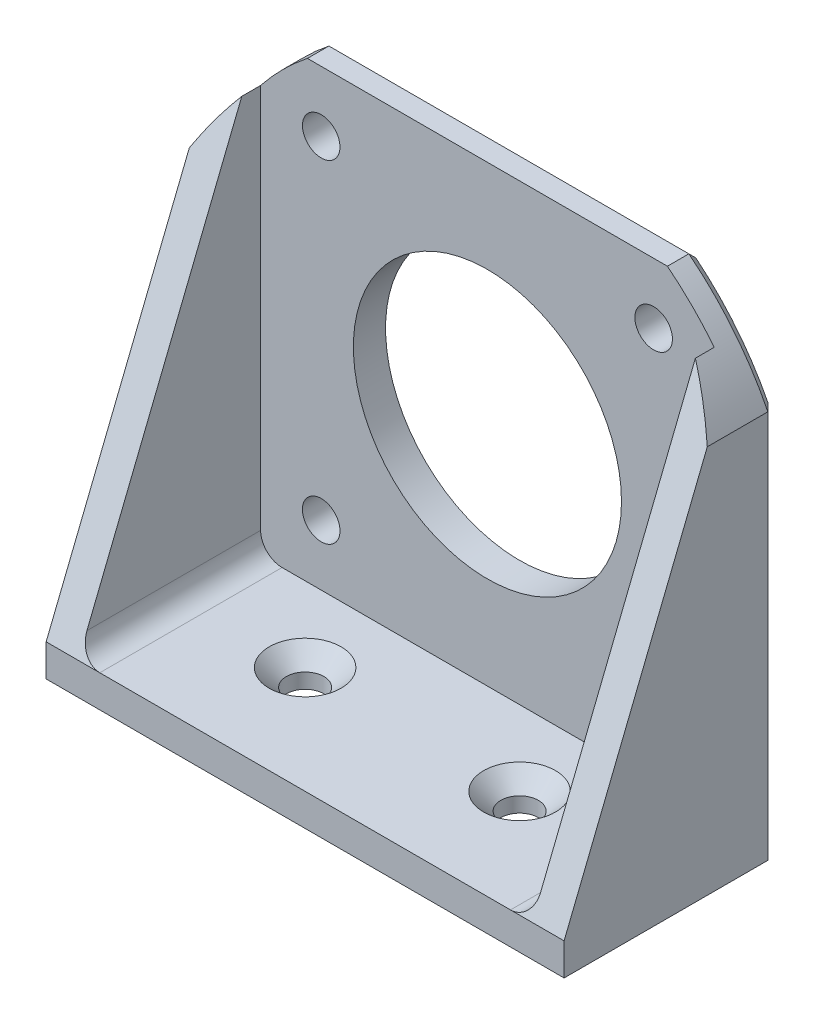
from build123d import *

# Parameters (mm, degrees)
SKETCH1_W           = 48.3
SKETCH1_H           = 20
BOSS_EXTRUDE1_DEPTH = 3
SKETCH2_W           = 48.3
SKETCH2_H           = 3
BOSS_EXTRUDE2_DEPTH = 42.3
SKETCH3_R           = 12.5
SKETCH3_R_2         = 1.75
CUT_EXTRUDE1_DEPTH  = 55.076912819
RIB1_REACH          = 68.97
SKETCH4_WALL_W      = 181.528252596
SKETCH4_WALL_H      = 3
CUT_EXTRUDE2_DEPTH  = 56.093670235
SKETCH6_R           = 1.75
CUT_EXTRUDE3_DEPTH  = 50.724365255
FILLET1_R           = 2
CHAMFER2_SIZE       = 1
CHAMFER3_SIZE       = 1.6


with BuildPart() as part:
    # Sketch1 → Boss-Extrude1 (new body)
    with BuildSketch(Plane(origin=(0, 0, 0), x_dir=(1, 0, 0), z_dir=(0, 1, 0))):
        Rectangle(SKETCH1_W, SKETCH1_H)
    extrude(amount=BOSS_EXTRUDE1_DEPTH)

    # Sketch2 → Boss-Extrude2 (add)
    with BuildSketch(Plane(origin=(0, 3, 0), x_dir=(1, 0, 0), z_dir=(0, 1, 0))):
        with Locations((0, 8.5)):
            Rectangle(SKETCH2_W, SKETCH2_H)
    extrude(amount=BOSS_EXTRUDE2_DEPTH)

    # Sketch3 → Cut-Extrude1 (cut, through all)
    with BuildSketch(Plane.XY.offset(-7)):
        with Locations((0, 24.15)):
            Circle(SKETCH3_R)
        with Locations((-15.5, 39.65)):
            Circle(SKETCH3_R_2)
        with Locations((15.5, 39.65)):
            Circle(SKETCH3_R_2)
        with Locations((15.5, 8.65)):
            Circle(SKETCH3_R_2)
        with Locations((-15.5, 8.65)):
            Circle(SKETCH3_R_2)
    extrude(amount=-CUT_EXTRUDE1_DEPTH, mode=Mode.SUBTRACT)

    # Sketch4 wall → Rib1 (add, up to next)
    with BuildSketch(Plane(origin=(-24.15, 24.15, 1.5), x_dir=(0, -0.927870342081, 0.372902974359), z_dir=(0, 0.372902974359, 0.927870342081)), mode=Mode.PRIVATE) as rib1_sk1:
        with Locations((0, 1.5)):
            Rectangle(SKETCH4_WALL_W, SKETCH4_WALL_H)
    rib1_tool1 = extrude(rib1_sk1.sketch, amount=-RIB1_REACH, mode=Mode.PRIVATE) - part.part
    rib1 = rib1_tool1.solids().sort_by_distance((-24.15, 24.15, 1.5))[0]
    add(rib1)

    # Mirror1: Rib1 across plane
    add(rib1.mirror(Plane(origin=(0, 0, 0), x_dir=(0, 0, 1), z_dir=(1, 0, 0))))

    # Sketch5 → Cut-Extrude2 (cut, through all)
    with BuildSketch(Plane(origin=(0, 0, -10), x_dir=(-1, 0, 0), z_dir=(0, 0, -1))):
        with BuildLine():
            Line((-27, 24.15), (-32.102102735, 24.15))
            ThreePointArc((-32.102102735, 24.15), (0, 56.252102735), (32.102102735, 24.15))
            Line((32.102102735, 24.15), (27, 24.15))
            ThreePointArc((27, 24.15), (0, 51.15), (-27, 24.15))
        make_face()
    extrude(amount=-CUT_EXTRUDE2_DEPTH, mode=Mode.SUBTRACT)

    # Sketch6 → Cut-Extrude3 (cut, through all)
    with BuildSketch(Plane(origin=(0, 3, 0), x_dir=(1, 0, 0), z_dir=(0, 1, 0))):
        with Locations(Location((-10, 0, 0), (0, 0, 270))):
            Circle(SKETCH6_R)
        with Locations(Location((10, 0, 0), (0, 0, 270))):
            Circle(SKETCH6_R)
    extrude(amount=-CUT_EXTRUDE3_DEPTH, mode=Mode.SUBTRACT)

    # Fillet1
    fillet1_edges = [part.edges().sort_by_distance(p)[0] for p in [
        (-21.15, 3, 1.5),
        (21.15, 3, 1.5),
    ]]
    fillet(fillet1_edges, radius=FILLET1_R)

    # Chamfer2
    chamfer2_edges = [part.edges().sort_by_distance(p)[0] for p in [
        (0, 0, -10),
        (0, 45.3, -10),
        (-24.15, 18.111917674, -10),
        (24.15, 18.111917674, -10),
        (20.963705349, 41.165377106, -10),
        (-20.963705349, 41.165377106, -10),
    ]]
    chamfer(chamfer2_edges, length=CHAMFER2_SIZE)

    # Chamfer3
    chamfer3_edges = [part.edges().sort_by_distance(p)[0] for p in [
        (-10, 3, -1.75),
        (10, 3, -1.75),
    ]]
    chamfer(chamfer3_edges, length=CHAMFER3_SIZE)


solid = part.part
